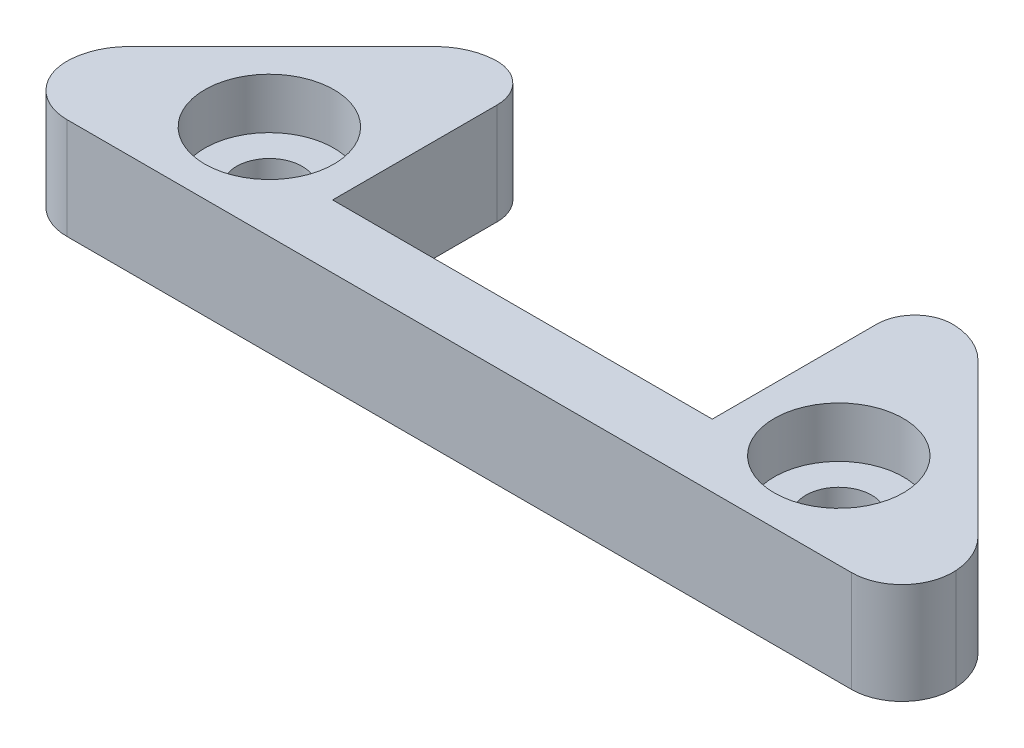
from build123d import *

# Parameters (mm, degrees)
ESQUISSE1_R             = 2.6
BOSS_EXTRU_1_DEPTH      = 8
ESQUISSE3_R             = 5.1
ENL_V_MAT_EXTRU_2_DEPTH = 4
ESQUISSE4_R             = 5.5
ESQUISSE4_R_2           = 4.5
ENL_V_MAT_EXTRU_3_DEPTH = 2
CONG_1_R                = 5
CONG_2_R                = 3
CONG_3_R                = 4


with BuildPart() as part:
    # Esquisse1 → Boss.-Extru.1 (new body)
    with BuildSketch(Plane(origin=(0, 0, 0), x_dir=(1, 0, 0), z_dir=(0, 1, 0))):
        Polygon((-35, 0), (35, 0), (35, 6), (20, 21), (15, 21), (15, 5), (-15, 5), (-15, 21), (-20, 21), (-35, 6), align=None)
        with Locations((22.5, 7.5)):
            Circle(ESQUISSE1_R, mode=Mode.SUBTRACT)
        with Locations((-22.5, 7.5)):
            Circle(ESQUISSE1_R, mode=Mode.SUBTRACT)
    extrude(amount=BOSS_EXTRU_1_DEPTH)

    # Esquisse3 → Enlèv. mat.-Extru.2 (cut)
    with BuildSketch(Plane(origin=(0, 8, 0), x_dir=(1, 0, 0), z_dir=(0, 1, 0))):
        with Locations((-22.5, 7.5)):
            Circle(ESQUISSE3_R)
        with Locations((22.5, 7.5)):
            Circle(ESQUISSE3_R)
    extrude(amount=-ENL_V_MAT_EXTRU_2_DEPTH, mode=Mode.SUBTRACT)

    # Esquisse4 → Enlèv. mat.-Extru.3 (cut)
    with BuildSketch(Plane.XZ):
        with Locations((-22.5, -7.5)):
            Circle(ESQUISSE4_R)
        with Locations((-22.5, -7.5)):
            Circle(ESQUISSE4_R_2, mode=Mode.SUBTRACT)
        with Locations((22.5, -7.5)):
            Circle(ESQUISSE4_R)
        with Locations((22.5, -7.5)):
            Circle(ESQUISSE4_R_2, mode=Mode.SUBTRACT)
    extrude(amount=-ENL_V_MAT_EXTRU_3_DEPTH, mode=Mode.SUBTRACT)

    # Congé1
    cong_1_edges = [part.edges().sort_by_distance(p)[0] for p in [
        (-35, 4, -6),
        (-20, 4, -21),
        (20, 4, -21),
        (35, 4, -6),
    ]]
    fillet(cong_1_edges, radius=CONG_1_R)

    # Congé2
    cong_2_edges = [part.edges().sort_by_distance(p)[0] for p in [
        (-15, 4, -21),
        (15, 4, -21),
    ]]
    fillet(cong_2_edges, radius=CONG_2_R)

    # Congé3
    cong_3_edges = [part.edges().sort_by_distance(p)[0] for p in [
        (-35, 4, 0),
        (35, 4, 0),
    ]]
    fillet(cong_3_edges, radius=CONG_3_R)


solid = part.part
